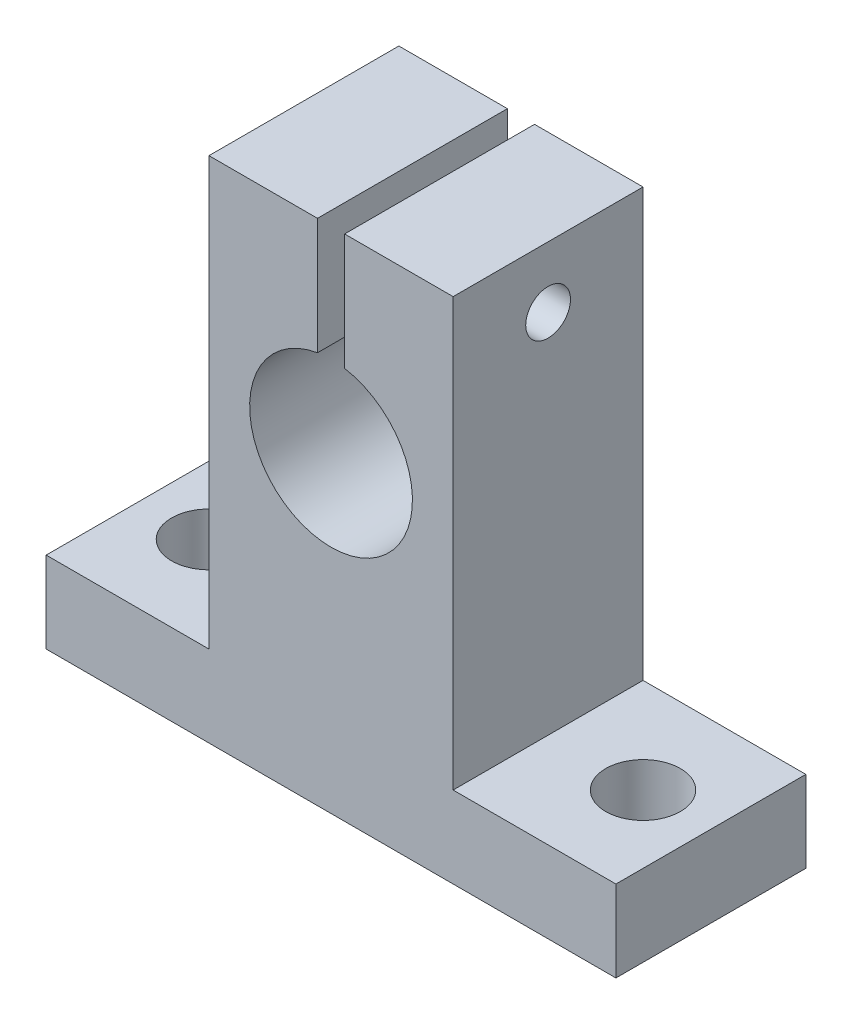
from build123d import *

# Parameters (mm, degrees)
BOSS_EXTRUDE1_DEPTH         = 14
TAP_DRILL_FOR_M4X0_7_TAP2_D = 3.3
F_12_0_12_DIAMETER_HOLE1_D  = 12
TAP_DRILL_FOR_M5X0_8_TAP1_D = 5.5


with BuildPart() as part:
    # Sketch2 → Boss-Extrude1 (new body)
    with BuildSketch(Plane.XY):
        Polygon((-1, 0), (-1, 14.5), (-9, 14.5), (-9, -17), (-21, -17), (-21, -23), (0, -23), (0, 0), align=None)
    boss_extrude1 = extrude(amount=BOSS_EXTRUDE1_DEPTH)

    # Mirror1: Boss-Extrude1 across plane
    add(boss_extrude1.mirror(Plane(origin=(0, -23, 14), x_dir=(0, 0, 1), z_dir=(-1, 0, 0))))

    # Tap Drill for M4x0.7 Tap2 (through all)
    with Locations(Plane.ZY.offset(9)):
        with Locations((7, 10)):
            Hole(TAP_DRILL_FOR_M4X0_7_TAP2_D / 2)

    # Ø12.0 (12) Diameter Hole1 (through all)
    with Locations(Plane(origin=(0, 0, 0), x_dir=(1, 0, 0), z_dir=(0, 0, -1))):
        with Locations((0, 0)):
            Hole(F_12_0_12_DIAMETER_HOLE1_D / 2)

    # Tap Drill for M5x0.8 Tap1 (through all)
    with Locations(Plane(origin=(0, -23, 0), x_dir=(-1, 0, 0), z_dir=(0, -1, 0))):
        with Locations((-16, -7), (16, -7)):
            Hole(TAP_DRILL_FOR_M5X0_8_TAP1_D / 2)


solid = part.part
